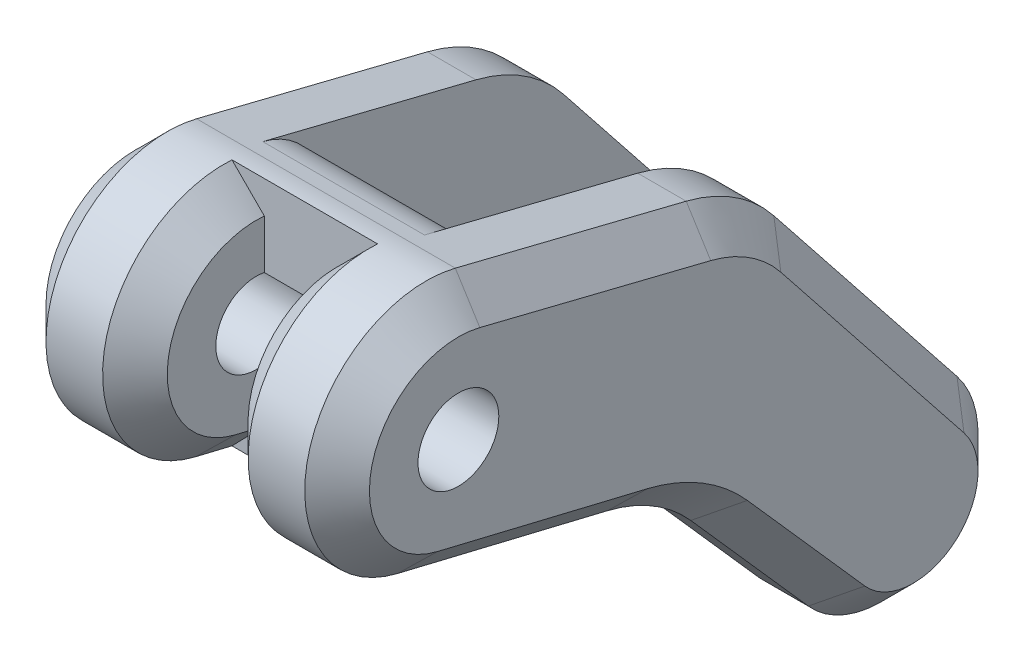
from build123d import *

# Parameters (mm, degrees)
SKETCH1_R               = 2.5
BOSS_EXTRUDE1_DEPTH     = 20
SKETCH2_W               = 10
SKETCH2_H               = 31.25301739
CUT_EXTRUDE1_DEPTH      = 26.258397403
CUT_EXTRUDE1_DEPTH_BACK = 7
FILLET1_R               = 5
CHAMFER1_SIZE           = 2
SKETCH4_R               = 2.5
BOSS_EXTRUDE2_DEPTH     = 20
SKETCH5_W               = 5
SKETCH5_H               = 8
CUT_EXTRUDE2_DEPTH      = 26.258397403
CUT_EXTRUDE2_DEPTH_BACK = 7
CHAMFER2_SIZE           = 2
SCALE1_SCALE            = 2


with BuildPart() as part:
    # Sketch1 → Boss-Extrude1 (new body)
    with BuildSketch(Plane(origin=(0, 0, 0), x_dir=(0, 0, -1), z_dir=(1, 0, 0))):
        with BuildLine():
            Line((-26.320929868, 25.036498407), (-12.043816775, 21.484201108))
            ThreePointArc((-12.043816775, 21.484201108), (-9.046440649, 20.189090541), (-6.626054873, 17.99744556))
            Line((-6.626054873, 17.99744556), (4.699352175, 3.730427474))
            ThreePointArc((4.699352175, 3.730427474), (3.853673118, -4.598826318), (-4.495069155, -3.974211028))
            Line((-4.495069155, -3.974211028), (-11.760416857, 4.243329543))
            ThreePointArc((-11.760416857, 4.243329543), (-14.097354711, 6.188634088), (-16.910883072, 7.341693702))
            Line((-16.910883072, 7.341693702), (-29.887785442, 10.466860499))
            ThreePointArc((-29.887785442, 10.466860499), (-35.416669297, 19.541837843), (-26.320929868, 25.036498407))
        make_face()
        Circle(SKETCH1_R, mode=Mode.SUBTRACT)
        with Locations((-28.13179866, 17.758397403)):
            Circle(SKETCH1_R, mode=Mode.SUBTRACT)
    extrude(amount=BOSS_EXTRUDE1_DEPTH)

    # Sketch2 → Cut-Extrude1 (cut, two sides)
    with BuildSketch(Plane(origin=(0, 0, 0), x_dir=(1, 0, 0), z_dir=(0, 1, 0))) as cut_extrude1_sk:
        with Locations((10, -5.807345092)):
            Rectangle(SKETCH2_W, SKETCH2_H)
    extrude(amount=CUT_EXTRUDE1_DEPTH, mode=Mode.SUBTRACT)
    extrude(cut_extrude1_sk.sketch, amount=-CUT_EXTRUDE1_DEPTH_BACK, mode=Mode.SUBTRACT)

    # Fillet1
    fillet1_edges = [part.edges().sort_by_distance(p)[0] for p in [
        (10, 23.820541998, 21.433853787),
        (10, 8.430939618, 21.433853787),
    ]]
    fillet(fillet1_edges, radius=FILLET1_R)

    # Chamfer1
    chamfer1_edges = [part.edges().sort_by_distance(p)[0] for p in [
        (20, 6.188634088, 14.097354711),
        (0, 8.904277101, 23.399334257),
        (0, 19.541837843, 35.416669297),
        (20, 0.134559258, 8.127743006),
        (20, -4.598826318, -3.853673118),
        (20, 10.863936517, 0.963351349),
        (20, 20.189090541, 9.046440649),
        (20, 23.260349758, 19.182373322),
        (20, 19.541837843, 35.416669297),
        (20, 8.904277101, 23.399334257),
        (0, 23.260349758, 19.182373322),
        (0, 20.189090541, 9.046440649),
        (0, 10.863936517, 0.963351349),
        (0, -4.598826318, -3.853673118),
        (0, 0.134559258, 8.127743006),
        (0, 6.188634088, 14.097354711),
    ]]
    chamfer(chamfer1_edges, length=CHAMFER1_SIZE)

    # Sketch4 → Boss-Extrude2 (add)
    with BuildSketch(Plane(origin=(20, 0, 0), x_dir=(0, 0, -1), z_dir=(1, 0, 0))):
        Circle(SKETCH4_R)
    extrude(amount=-BOSS_EXTRUDE2_DEPTH)

    # Sketch5 → Cut-Extrude2 (cut, two sides)
    with BuildSketch(Plane(origin=(0, 0, 0), x_dir=(1, 0, 0), z_dir=(0, 1, 0))) as cut_extrude2_sk:
        with Locations((10, -31.63179866)):
            Rectangle(SKETCH5_W, SKETCH5_H)
    extrude(amount=CUT_EXTRUDE2_DEPTH, mode=Mode.SUBTRACT)
    extrude(cut_extrude2_sk.sketch, amount=-CUT_EXTRUDE2_DEPTH_BACK, mode=Mode.SUBTRACT)

    # Chamfer2
    chamfer2_edges = [part.edges().sort_by_distance(p)[0] for p in [
        (7.5, 18.890459141, 35.545868812),
        (7.5, 10.195211119, 28.759792051),
        (12.5, 18.890459141, 35.545868812),
        (12.5, 10.195211119, 28.759792051),
    ]]
    chamfer(chamfer2_edges, length=CHAMFER2_SIZE)


with BuildPart() as part_1:
    # Scale1: scaled about (10, 12.009955127, 15.525619082)
    add(part.part.scale(SCALE1_SCALE).moved(Location((-10, -12.009955127, -15.525619082))))


solid = part_1.part
